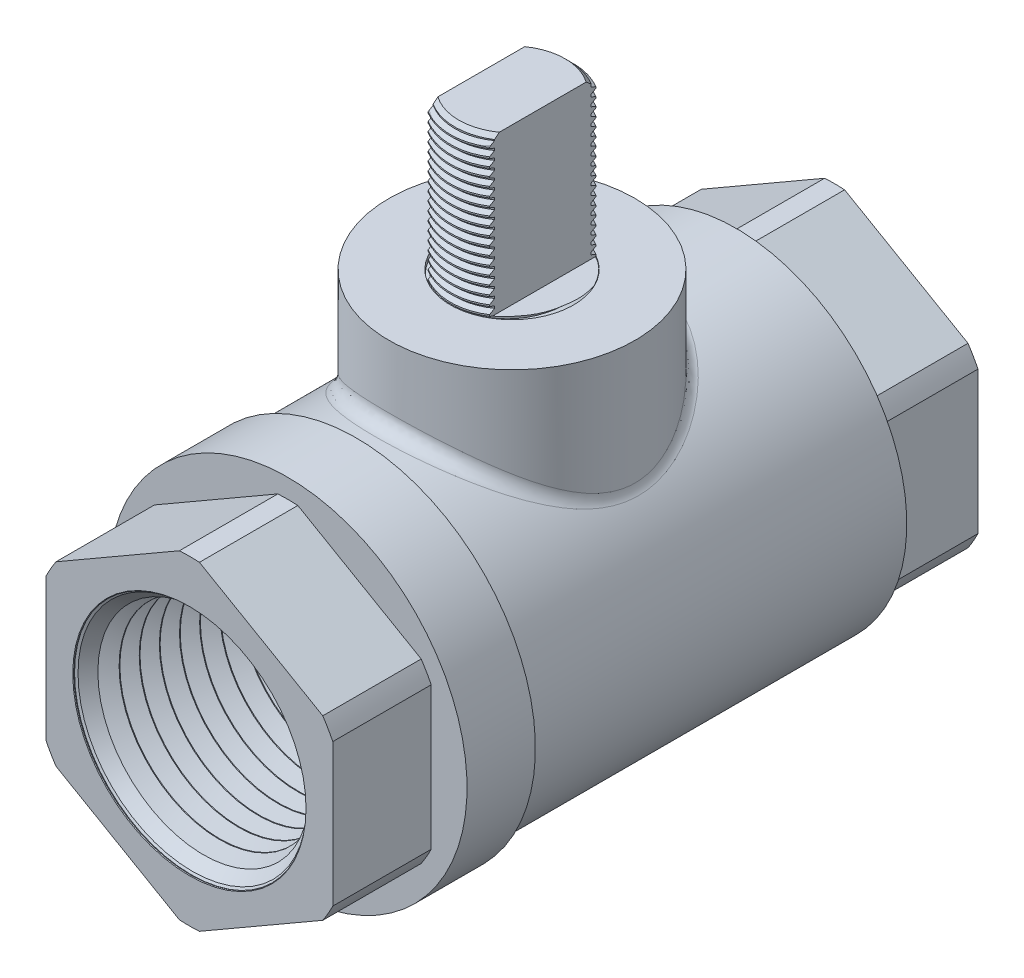
from build123d import *

# Parameters (mm, degrees)
EXTRUDE1_DEPTH       = 59.944
CHAMFER1_SIZE        = 0.762
FILLET5_R            = 1.27
LPATTERN1_COUNT      = 2
LPATTERN1_PITCH      = 0.79375
LPATTERN1_COL_COUNT  = 19
LPATTERN1_COL_PITCH  = 0.79375
SKETCH26_R           = 5.7277
EXTRUDE8_DEPTH       = 0.127
SKETCH16_W           = 9.144
SKETCH16_H           = 0.508
SKETCH27_OUTSIDE_W   = 52.774
SKETCH27_OUTSIDE_H   = 79.412
SKETCH27_OUTSIDE_W_2 = 5.7023
SKETCH27_OUTSIDE_H_2 = 11.4046
CUT_EXTRUDE3_DEPTH   = 14.478


with BuildPart() as part:
    # Sketch1 → Revolve1 (revolve)
    with BuildSketch(Plane(origin=(0, -2.929502347, 125.566843264), x_dir=(0, 0, -1), z_dir=(1, 0, 0)), mode=Mode.PRIVATE) as revolve1_sk:
        Polygon((140.044843264, 2.929502347), (140.044843264, 11.770110045), (140.077538974, 11.83106174), (140.86976871, 13.307944955), (140.938902281, 13.310105487), (141.821805796, 11.885572802), (141.890939366, 11.887733334), (142.683169103, 13.364616549), (142.752302674, 13.366777081), (143.635206188, 11.942244396), (143.704339759, 11.944404928), (144.496569495, 13.421288143), (144.565703066, 13.423448675), (145.448606581, 11.99891599), (145.517740151, 12.001076522), (146.309969888, 13.477959737), (146.379103459, 13.480120269), (147.262006973, 12.055587585), (147.331140544, 12.057748117), (148.12337028, 13.534631332), (148.192503851, 13.536791864), (149.075407366, 12.112259179), (149.144540936, 12.114419711), (149.936770673, 13.591302926), (150.005904244, 13.593463458), (150.888807758, 12.168930773), (150.957941329, 12.171091305), (151.750171065, 13.64797452), (151.819304636, 13.650135052), (152.702208151, 12.225602367), (152.771341721, 12.227762899), (153.563571458, 13.704646114), (153.632705029, 13.706806647), (154.515608543, 12.282273962), (154.584742114, 12.284434494), (155.37697185, 13.761317709), (155.446105421, 13.763478241), (156.329008935, 12.338945556), (156.398142506, 12.341106088), (157.190372243, 13.817989303), (157.259505814, 13.820149835), (158.142409328, 12.39561715), (158.211542899, 12.397777682), (159.003772635, 13.874660897), (159.072906206, 13.876821429), (159.95580972, 12.452288744), (160.024943291, 12.454449276), (160.817173028, 13.931332492), (160.886306598, 13.933493024), (161.769210113, 12.508960339), (161.838343684, 12.511120871), (162.63057342, 13.988004086), (162.699706991, 13.990164618), (163.582610505, 12.565631933), (163.651744076, 12.567792465), (164.443973813, 14.04467568), (164.513107383, 14.046836212), (165.396010898, 12.622303527), (165.465144469, 12.624464059), (166.257374205, 14.101347274), (166.326507776, 14.103507806), (167.20941129, 12.678975121), (167.278544861, 12.681135654), (167.278544861, 2.929502347), align=None)
    revolve(revolve1_sk.sketch.rotate(Axis((0, 0, -14.478), (0, 0, 1)), 90), axis=Axis((0, 0, -14.478), (0, 0, 1)))

    # Sketch6 → Cut-Revolve3 (revolve, cut)
    with BuildSketch(Plane(origin=(0, 0, 0), x_dir=(0, 0, -1), z_dir=(1, 0, 0)), mode=Mode.PRIVATE) as cut_revolve3_sk:
        Polygon((29.972, 0), (29.972, 10.836874096), (41.711701597, 11.203758105), (41.711701597, 0), align=None)
    revolve(cut_revolve3_sk.sketch.rotate(Axis((0, 0, -41.711701597), (0, 0, 1)), 180), axis=Axis((0, 0, -41.711701597), (0, 0, 1)), mode=Mode.SUBTRACT)

    # Sketch7 → Revolve3 (revolve)
    with BuildSketch(Plane(origin=(0, 0, 0), x_dir=(0, 0, -1), z_dir=(1, 0, 0)), mode=Mode.PRIVATE) as revolve3_sk:
        Polygon((28.0416, 9.324421283), (29.972, 10.836874096), (29.972, 9.384749298), align=None)
        Polygon((0, 0), (14.478, 0), (14.478, 8.840607698), (11.987392302, 6.35), (0, 6.35), align=None)
    revolve(revolve3_sk.sketch.rotate(Axis((0, 0, -14.478), (0, 0, -1)), 270), axis=Axis((0, 0, -14.478), (0, 0, -1)))

    # Mirror2: part across plane


with BuildPart() as part_1:
    add(part.part)
    add(part.part.mirror(Plane.XY))


with BuildPart() as body_2:
    # Sketch8 → Extrude1 (new body)
    with BuildSketch(Plane.XY.offset(29.972)):
        Polygon((0, 15.383266982), (-13.3223, 7.691633491), (-13.3223, -7.691633491), (0, -15.383266982), (13.3223, -7.691633491), (13.3223, 7.691633491), align=None)
    extrude(amount=-EXTRUDE1_DEPTH)

    # Sketch9 → Revolve4 (revolve)
    with BuildSketch(Plane(origin=(0, 0, 0), x_dir=(0, 0, -1), z_dir=(1, 0, 0)), mode=Mode.PRIVATE) as revolve4_sk:
        Polygon((-20.828, 7.691633491), (-20.828, 16.652875), (-14.478, 16.652875), (-14.478, 16.183884258), (-14.146373466, 15.852257724), (20.828, 15.852257724), (20.828, 7.691633491), align=None)
    revolve(revolve4_sk.sketch.rotate(Axis((0, 0, 0), (0, 0, 1)), 270), axis=Axis((0, 0, 0), (0, 0, 1)))

    # Sketch10 → Revolve5 (revolve)
    with BuildSketch(Plane(origin=(0, 0, 0), x_dir=(0, 0, -1), z_dir=(1, 0, 0))):
        Polygon((0, 1.27), (0, 22.176857724), (5.7277, 22.176857724), (5.7277, 22.964257724), (11.43, 22.964257724), (11.43, 1.27), align=None)
        Polygon((5.7023, 22.964257724), (5.7023, 37.442257724), (0, 37.442257724), (0, 22.202257724), (5.7023, 22.202257724), align=None)
    revolve(axis=Axis((0, 0, 0), (0, 1, 0)))


with BuildPart() as revolve5_piece_1:
    # of the separate pieces the step leaves, piece 1, a body of its own (revolve5_pieces)
    add(body_2.part.solids().sort_by_distance((0, 15.383266982, 29.972))[0])

    # Fillet5
    fillet5_edges = [revolve5_piece_1.edges().sort_by_distance(p)[0] for p in [
        (0, 15.852257724, 11.43),
    ]]
    fillet(fillet5_edges, radius=FILLET5_R)



with BuildPart() as revolve5_piece_2:
    # of the separate pieces the step leaves, piece 2, a body of its own (revolve5_pieces)
    add(body_2.part.solids().sort_by_distance((0, 37.442257724, -5.7023))[0])

    # Chamfer1
    chamfer1_edges = [revolve5_piece_2.edges().sort_by_distance(p)[0] for p in [
        (0, 37.442257724, 5.7023),
    ]]
    chamfer(chamfer1_edges, length=CHAMFER1_SIZE)

    # Sketch20 → Cut-Revolve6 (revolve, cut)
    with BuildSketch(Plane(origin=(0, 0, 0), x_dir=(0, 0, -1), z_dir=(1, 0, 0)), mode=Mode.PRIVATE) as cut_revolve6_sk:
        Polygon((5.709188872, 37.343278414), (5.757410974, 36.650423245), (5.311595811, 36.86804183), (5.297818067, 37.06600045), align=None)
    cut_revolve6 = revolve(cut_revolve6_sk.sketch.rotate(Axis((0, 37.442257724, 0.058772234), (0, -0.997586745890785, -0.06943114879529476)), 180), axis=Axis((0, 37.442257724, 0.058772234), (0, -0.997586745890785, -0.06943114879529476)), mode=Mode.SUBTRACT)

    # LPattern1: Cut-Revolve6 ×2
    with Locations(*[(0, i * LPATTERN1_PITCH, 0) for i in range(1, LPATTERN1_COUNT)]):
        add(cut_revolve6, mode=Mode.SUBTRACT)

    # LPattern1 col: Cut-Revolve6 ×19
    with Locations(*[(0, -i * LPATTERN1_COL_PITCH, 0) for i in range(1, LPATTERN1_COL_COUNT)]):
        add(cut_revolve6, mode=Mode.SUBTRACT)


with BuildPart() as revolve5_piece_1_1:
    add(revolve5_piece_1.part)

    add(revolve5_piece_2.part)  # Extrude8 merges Revolve5 piece 2
    # Sketch26 → Extrude8 (add)
    with BuildSketch(Plane(origin=(0, 22.176857724, 0), x_dir=(-1, 0, 0), z_dir=(0, 1, 0))):
        with Locations(Location((0, 0, 0), (0, 0, 270))):
            Circle(SKETCH26_R)
    extrude(amount=EXTRUDE8_DEPTH)

    # Sketch16 → Cut-Revolve5 (revolve, cut)
    with BuildSketch(Plane(origin=(0, 0, 0), x_dir=(0, 0, -1), z_dir=(1, 0, 0)), mode=Mode.PRIVATE) as cut_revolve5_sk:
        with Locations((25.4, 15.129266982)):
            Rectangle(SKETCH16_W, SKETCH16_H)
        with Locations((-25.4, 15.129266982)):
            Rectangle(SKETCH16_W, SKETCH16_H)
    revolve(cut_revolve5_sk.sketch.rotate(Axis((0, 0, 0), (0, 0, 1)), 270), axis=Axis((0, 0, 0), (0, 0, 1)), mode=Mode.SUBTRACT)

    # Combine1: cut part
    add(part_1.part, mode=Mode.SUBTRACT)

    # Sketch27 outside → Cut-Extrude3 (cut)
    with BuildSketch(Plane(origin=(0, 37.442257724, 0), x_dir=(-1, 0, 0), z_dir=(0, 1, 0))):
        Rectangle(SKETCH27_OUTSIDE_W, SKETCH27_OUTSIDE_H)
        Rectangle(SKETCH27_OUTSIDE_W_2, SKETCH27_OUTSIDE_H_2, mode=Mode.SUBTRACT)
    extrude(amount=-CUT_EXTRUDE3_DEPTH, mode=Mode.SUBTRACT)


solid = revolve5_piece_1_1.part
